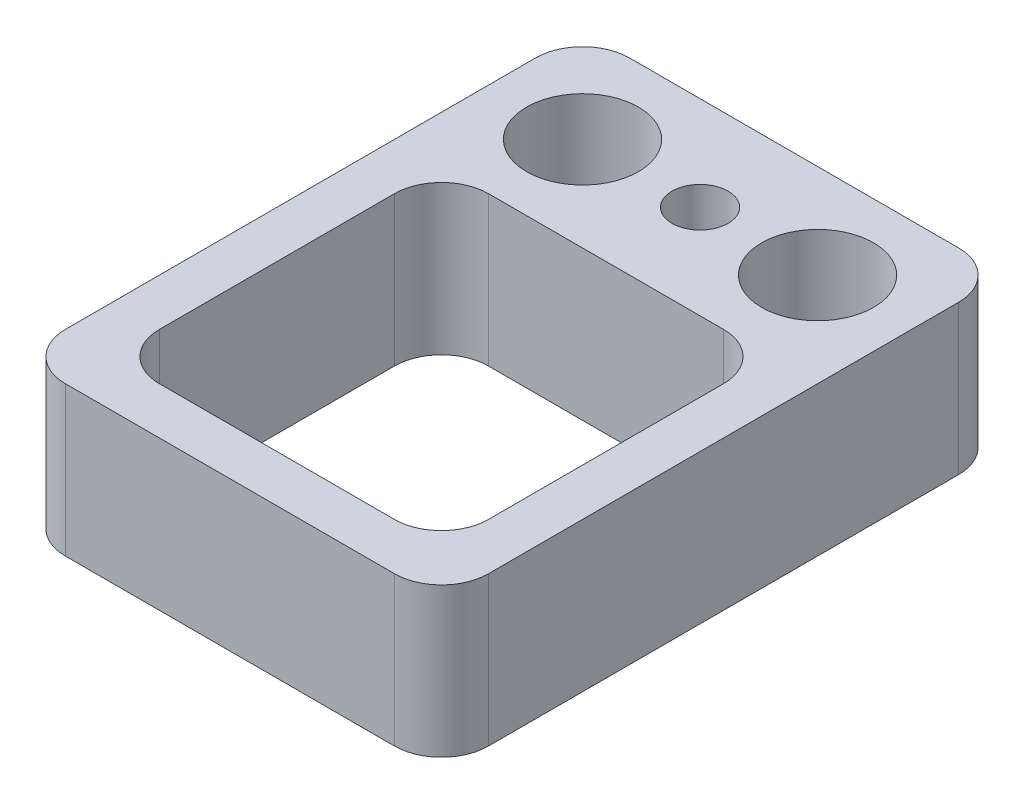
from build123d import *

# Parameters (mm, degrees)
SKETCH1_W                           = 9
SKETCH1_H                           = 12
EXTRUDE1_DEPTH                      = 3.175
SKETCH2_W                           = 7
SKETCH2_H                           = 7
EXTRUDE2_DEPTH                      = 3.5
F_0_80_TAPPED_HOLE1_D               = 1.19126
F_0_80_TAPPED_HOLE1_DEPTH           = 4
F_0_80_TAPPED_HOLE1_TIP             = 0.357890611
F_3_32_0_09375_DIAMETER_HOLE1_D     = 2.38125
F_3_32_0_09375_DIAMETER_HOLE1_DEPTH = 10
F_3_32_0_09375_DIAMETER_HOLE1_TIP   = 0.715399675
FILLET7_R                           = 1


with BuildPart() as part:
    # Sketch1 → Extrude1 (new body)
    with BuildSketch(Plane(origin=(0, 0, 0), x_dir=(1, 0, 0), z_dir=(0, 1, 0))):
        Rectangle(SKETCH1_W, SKETCH1_H)
    extrude(amount=EXTRUDE1_DEPTH)

    # Sketch2 → Extrude2 (cut)
    with BuildSketch(Plane(origin=(0, 3.175, 0), x_dir=(1, 0, 0), z_dir=(0, 1, 0))):
        with Locations((0, -1.5)):
            Rectangle(SKETCH2_W, SKETCH2_H)
    extrude(amount=-EXTRUDE2_DEPTH, mode=Mode.SUBTRACT)

    # #0-80 Tapped Hole1
    with Locations(Plane(origin=(0, 3.175, -4), x_dir=(0, 0, 1), z_dir=(0, 1, 0))):
        with Locations((0, 0)):
            Hole(F_0_80_TAPPED_HOLE1_D / 2, depth=F_0_80_TAPPED_HOLE1_DEPTH)
            with Locations((0, 0, -(F_0_80_TAPPED_HOLE1_DEPTH + F_0_80_TAPPED_HOLE1_TIP / 2))):  # 118° drill point
                Cone(0, F_0_80_TAPPED_HOLE1_D / 2, F_0_80_TAPPED_HOLE1_TIP, mode=Mode.SUBTRACT)

    # 3/32 (0.09375) Diameter Hole1
    with Locations(Plane(origin=(-2.5, 3.175, -4), x_dir=(0, 0, 1), z_dir=(0, 1, 0))):
        with Locations((0, 0), (0, 5)):
            Hole(F_3_32_0_09375_DIAMETER_HOLE1_D / 2, depth=F_3_32_0_09375_DIAMETER_HOLE1_DEPTH)
            with Locations((0, 0, -(F_3_32_0_09375_DIAMETER_HOLE1_DEPTH + F_3_32_0_09375_DIAMETER_HOLE1_TIP / 2))):  # 118° drill point
                Cone(0, F_3_32_0_09375_DIAMETER_HOLE1_D / 2, F_3_32_0_09375_DIAMETER_HOLE1_TIP, mode=Mode.SUBTRACT)

    # Fillet7
    fillet7_edges = [part.edges().sort_by_distance(p)[0] for p in [
        (-3.5, 1.5875, 5),
        (-3.5, 1.5875, -2),
        (3.5, 1.5875, -2),
        (3.5, 1.5875, 5),
        (-4.5, 1.5875, -6),
        (4.5, 1.5875, -6),
        (4.5, 1.5875, 6),
        (-4.5, 1.5875, 6),
    ]]
    fillet(fillet7_edges, radius=FILLET7_R)


solid = part.part
